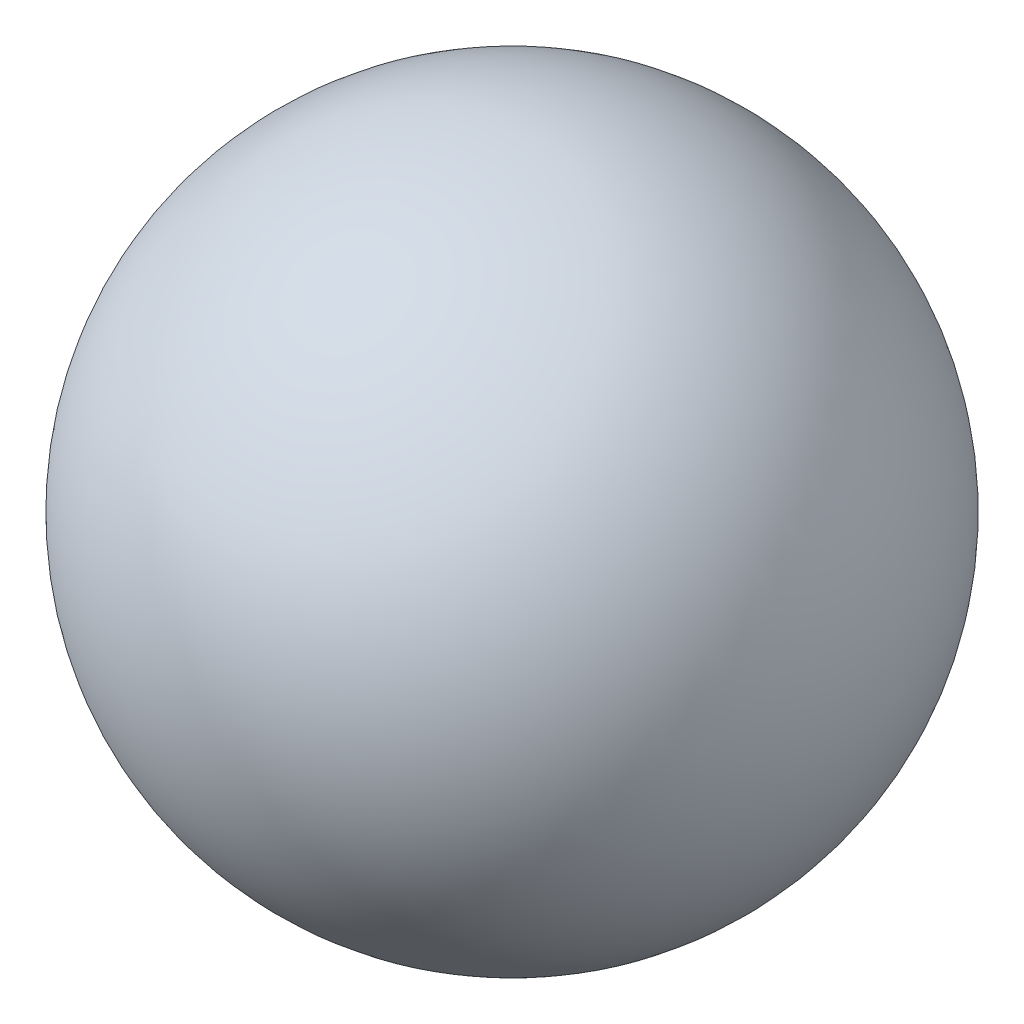
from build123d import *


with BuildPart() as part:
    # Sketch1 → Revolve1 (revolve)
    with BuildSketch(Plane.XY):
        with BuildLine():
            Line((0, 31.5), (0, -31.5))
            ThreePointArc((0, -31.5), (-31.5, 0), (0, 31.5))
        make_face()
    revolve(axis=Axis((0, 31.5, 0), (0, -1, 0)))


solid = part.part
